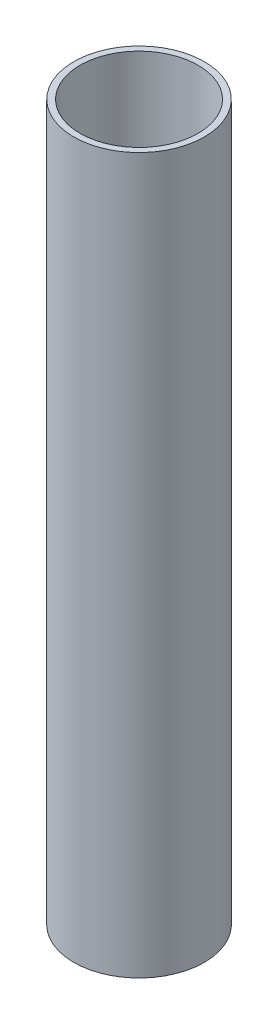
from build123d import *

# Parameters (mm, degrees)
SKETCH1_R           = 21
SKETCH1_R_2         = 19
EXTRUDE_THIN1_DEPTH = 230


with BuildPart() as part:
    # Sketch1 → Extrude-Thin1 (new body)
    with BuildSketch(Plane(origin=(0, 0, 0), x_dir=(1, 0, 0), z_dir=(0, 1, 0))):
        Circle(SKETCH1_R)
        Circle(SKETCH1_R_2, mode=Mode.SUBTRACT)
    extrude(amount=EXTRUDE_THIN1_DEPTH)


solid = part.part
